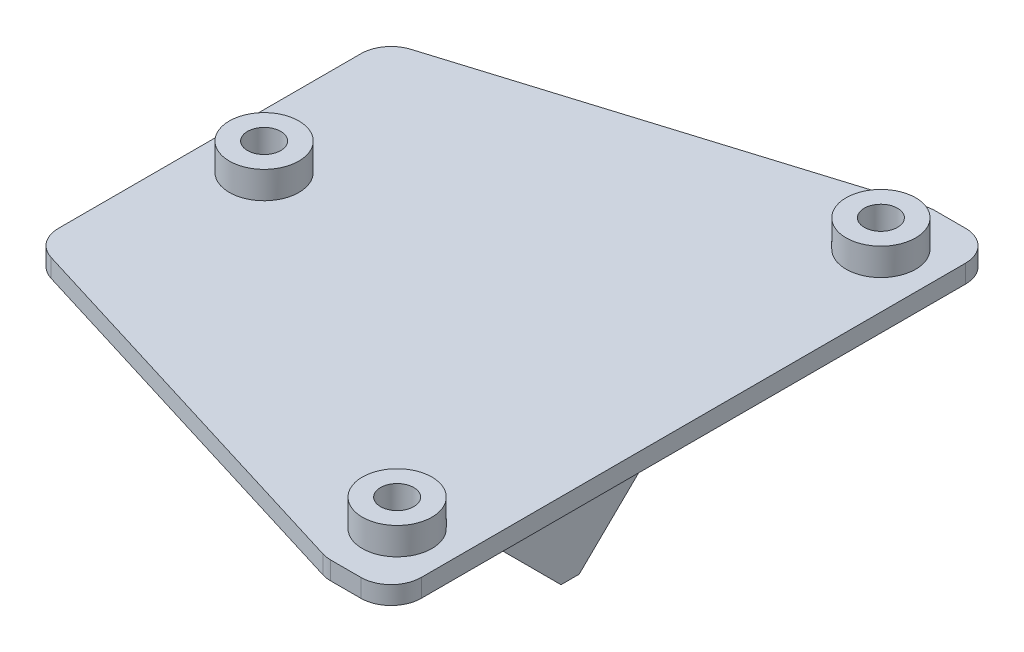
from build123d import *

# Parameters (mm, degrees)
BOSS_EXTRUDE1_DEPTH     = 3
SKETCH2_R               = 2.75
CUT_EXTRUDE1_DEPTH      = 65.101482042
BOSS_EXTRUDE3_START     = 4.5
SKETCH3_2_R             = 5.75
SKETCH3_2_R_2           = 2.75
BOSS_EXTRUDE3_DEPTH     = 4.5
CUT_EXTRUDE2_DEPTH      = 4.5
BOSS_EXTRUDE4_DEPTH     = 30
CUT_EXTRUDE3_DEPTH      = 82.262291378
CUT_EXTRUDE3_DEPTH_BACK = 82.262291378
CUT_EXTRUDE4_DEPTH      = 72.779175253
CUT_EXTRUDE4_DEPTH_BACK = 72.779175253
SKETCH9_R               = 8
SKETCH9_R_2             = 1.75


with BuildPart() as part:
    # Sketch1 → Boss-Extrude1 (new body)
    with BuildSketch(Plane(origin=(0, 0, 0), x_dir=(1, 0, 0), z_dir=(0, 1, 0))):
        with BuildLine():
            Line((-35, 50), (35, 50))
            ThreePointArc((35, 50), (38.535533906, 48.535533906), (40, 45))
            Line((40, 45), (40, -45))
            ThreePointArc((40, -45), (38.535533906, -48.535533906), (35, -50))
            Line((35, -50), (-35, -50))
            ThreePointArc((-35, -50), (-38.535533906, -48.535533906), (-40, -45))
            Line((-40, -45), (-40, 45))
            ThreePointArc((-40, 45), (-38.535533906, 48.535533906), (-35, 50))
        make_face()
    extrude(amount=BOSS_EXTRUDE1_DEPTH)

    # Sketch2 → Cut-Extrude1 (cut, through all)
    with BuildSketch(Plane(origin=(0, 3, 0), x_dir=(1, 0, 0), z_dir=(0, 1, 0))):
        with Locations((-31, 0)):
            Circle(SKETCH2_R)
        with Locations((31, 40)):
            Circle(SKETCH2_R)
        with Locations((31, -40)):
            Circle(SKETCH2_R)
    extrude(amount=-CUT_EXTRUDE1_DEPTH, mode=Mode.SUBTRACT)

    # Sketch3_2 → Boss-Extrude3 (add)
    # profile 1 of 3: a face of its own
    with BuildSketch(Plane(origin=(0, 3, 0), x_dir=(1, 0, 0), z_dir=(0, 1, 0)).offset(BOSS_EXTRUDE3_START)):
        with Locations((-31, 0)):
            Circle(SKETCH3_2_R)
        with Locations((-31, 0)):
            Circle(SKETCH3_2_R_2, mode=Mode.SUBTRACT)
    # profile 2 of 3: a face of its own
    with BuildSketch(Plane(origin=(0, 3, 0), x_dir=(1, 0, 0), z_dir=(0, 1, 0)).offset(BOSS_EXTRUDE3_START)):
        with Locations((31, 40)):
            Circle(SKETCH3_2_R)
        with Locations((31, 40)):
            Circle(SKETCH3_2_R_2, mode=Mode.SUBTRACT)
    # profile 3 of 3: a face of its own
    with BuildSketch(Plane(origin=(0, 3, 0), x_dir=(1, 0, 0), z_dir=(0, 1, 0)).offset(BOSS_EXTRUDE3_START)):
        with Locations((31, -40)):
            Circle(SKETCH3_2_R)
        with Locations((31, -40)):
            Circle(SKETCH3_2_R_2, mode=Mode.SUBTRACT)
    extrude(amount=-BOSS_EXTRUDE3_DEPTH)

    # Sketch6 → Cut-Extrude2 (cut)
    with BuildSketch(Plane(origin=(0, 3, 0), x_dir=(1, 0, 0), z_dir=(0, 1, 0))):
        with BuildLine():
            Line((-36.470429244, -29.778895044), (28.529570756, -49.778895044))
            ThreePointArc((28.529570756, -49.778895044), (29.25652008, -49.944414789), (30, -50))
            Line((30, -50), (-40, -50))
            Line((-40, -50), (-40, -25))
            ThreePointArc((-40, -25), (-39.021948919, -27.970509534), (-36.470429244, -29.778895044))
        make_face()
        with BuildLine():
            Line((-40, 50), (30, 50))
            ThreePointArc((30, 50), (29.25652008, 49.944414789), (28.529570756, 49.778895044))
            Line((28.529570756, 49.778895044), (-36.470429244, 29.778895044))
            ThreePointArc((-36.470429244, 29.778895044), (-39.021948919, 27.970509534), (-40, 25))
            Line((-40, 25), (-40, 50))
        make_face()
    extrude(amount=-CUT_EXTRUDE2_DEPTH, mode=Mode.SUBTRACT)

    # Sketch7 → Boss-Extrude4 (add)
    with BuildSketch(Plane.XZ):
        Polygon((19.6, 6.770211843), (19.6, -6.770211843), (19.6, -31.5), (16.6, -31.5), (16.6, -1.5), (-16.6, -1.5), (-16.6, -31.5), (-19.6, -31.5), (-19.6, -6.770211843), (-19.6, 6.770211843), (-19.6, 31.5), (-16.6, 31.5), (-16.6, 1.5), (16.6, 1.5), (16.6, 31.5), (19.6, 31.5), align=None)
    extrude(amount=BOSS_EXTRUDE4_DEPTH)

    # Sketch8 → Cut-Extrude3 (cut, two sides: drawn at the far end of the back side and taken through both)
    with BuildSketch(Plane.ZY.offset(-16.6).offset(-CUT_EXTRUDE3_DEPTH_BACK)):
        Polygon((1.5, -30), (31.5, 0), (31.5, -30), align=None)
        Polygon((-1.5, -30), (-31.5, -30), (-31.5, -0.712729134), align=None)
    extrude(amount=CUT_EXTRUDE3_DEPTH + CUT_EXTRUDE3_DEPTH_BACK, mode=Mode.SUBTRACT)

    # Sketch9 → Cut-Extrude4 (cut, two sides: drawn at the far end of the back side and taken through both)
    with BuildSketch(Plane(origin=(0, 0, -1.5), x_dir=(-1, 0, 0), z_dir=(0, 0, -1)).offset(-CUT_EXTRUDE4_DEPTH_BACK)):
        with Locations((0, -15)):
            Circle(SKETCH9_R)
        with Locations((-8.838834765, -23.838834765)):
            Circle(SKETCH9_R_2)
        with Locations((-8.838834765, -6.161165235)):
            Circle(SKETCH9_R_2)
        with Locations((8.838834765, -23.838834765)):
            Circle(SKETCH9_R_2)
        with Locations((8.838834765, -6.161165235)):
            Circle(SKETCH9_R_2)
    extrude(amount=CUT_EXTRUDE4_DEPTH + CUT_EXTRUDE4_DEPTH_BACK, mode=Mode.SUBTRACT)


solid = part.part
